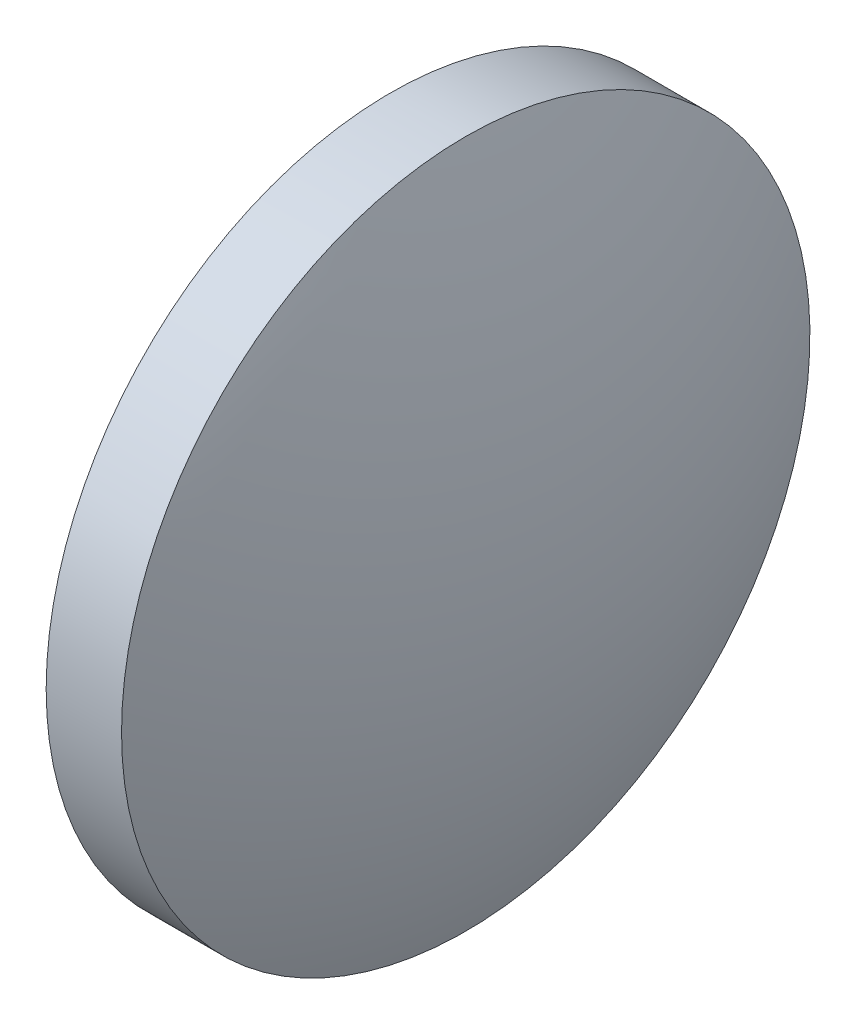
from build123d import *


with BuildPart() as part:
    # 草图2 → 旋转2 (revolve)
    with BuildSketch(Plane.XY):
        with BuildLine():
            Line((551.266574236, 125.172067176), (551.266574236, 135.172067176))
            Line((551.266574236, 135.172067176), (553.456574236, 135.172067176))
            ThreePointArc((553.456574236, 135.172067176), (554.959098868, 130.272069627), (555.466574236, 125.172067176))
            Line((555.466574236, 125.172067176), (551.266574236, 125.172067176))
        make_face()
    revolve(axis=Axis((548.863053355, 125.172067176, 0), (1, 0, 0)))


solid = part.part
